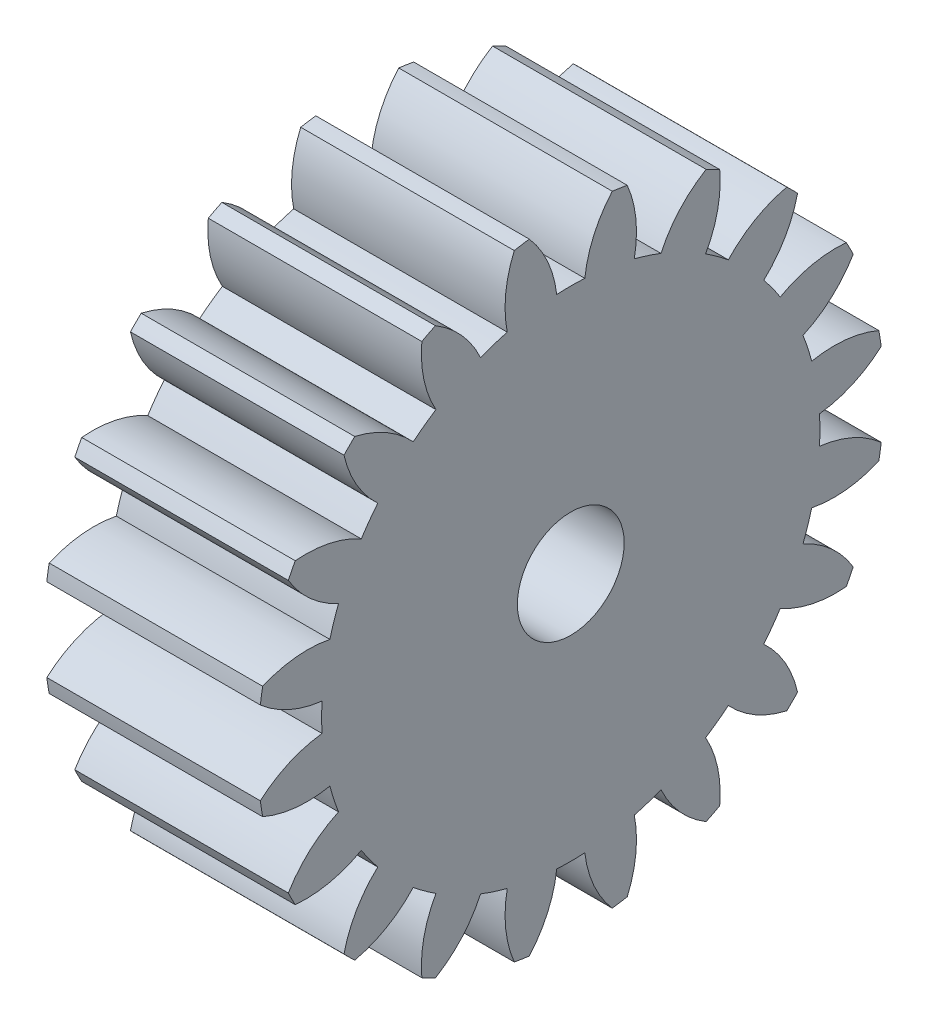
from build123d import *
from build123d.topology import SkipClean

# Parameters (mm, degrees)
BASPROSKE_W                  = 20
BASPROSKE_H                  = 55
TOOTHCUT_DEPTH               = 81.311892021
TEETHCUTS_COUNT              = 20
TEETHCUTS_ANGLE              = 342
BORSKE_R                     = 7.5
BORE_DEPTH                   = 50.0000508
SCALA1_SCALE                 = 0.16
ESTRUSIONE_ESTRUSIONE1_DEPTH = 2.8
SCHIZZO2_R                   = 2.85
TAGLIO_ESTRUSIONE1_DEPTH     = 3.3
SCHIZZO3_R                   = 1.5
TAGLIO_ESTRUSIONE2_DEPTH     = 3.3


with BuildPart() as part:
    # BasProSke → Base-Revolve (revolve)
    with BuildSketch(Plane(origin=(0, 0, 0), x_dir=(1, 0, 0), z_dir=(0, 1, 0))):
        with Locations((10, 27.5)):
            Rectangle(BASPROSKE_W, BASPROSKE_H)
    revolve(axis=Axis((-10, 0, 0), (1, 0, 0)))

    # TooCutSke → ToothCut (cut, through all)
    with BuildSketch(Plane(origin=(0, 0, 0), x_dir=(0, 0, -1), z_dir=(1, 0, 0))):
        with BuildLine():
            ThreePointArc((2.464838288, 43.679509764), (0, 43.749), (-2.464838288, 43.679509764))
            ThreePointArc((-2.464838288, 43.679509764), (-4.057398861, 49.476814676), (-7.300899231, 54.538899105))
            ThreePointArc((-7.300899231, 54.538899105), (0, 55.0254), (7.300899231, 54.538899105))
            ThreePointArc((7.300899231, 54.538899105), (4.057398861, 49.476814676), (2.464838288, 43.679509764))
        make_face()
    toothcut = extrude(amount=TOOTHCUT_DEPTH, mode=Mode.SUBTRACT)

    # TeethCuts: ToothCut ×20 about axis
    teethcuts_axis = Axis((-10, 0, 0), (1, 0, 0))
    for i in range(1, TEETHCUTS_COUNT):
        add(toothcut.rotate(teethcuts_axis, i * TEETHCUTS_ANGLE / (TEETHCUTS_COUNT - 1)), mode=Mode.SUBTRACT)

    # BorSke → Bore (cut, symmetric)
    with BuildSketch(Plane(origin=(0, 0, 0), x_dir=(0, 0, -1), z_dir=(1, 0, 0))):
        Circle(BORSKE_R)
    extrude(amount=BORE_DEPTH, both=True, mode=Mode.SUBTRACT)


with BuildPart() as part_1:
    # Scala1: scaled about (10, 0, 0)
    add(part.part.scale(SCALA1_SCALE).moved(Location((8.4, 0, 0))))

    # Schizzo1 → Estrusione-Estrusione1 (add)
    with SkipClean():  # the faces are left unmerged after this step: merging them gives an invalid solid
        with BuildSketch(Plane(origin=(11.6, 0, 0), x_dir=(0, 0, -1), z_dir=(1, 0, 0))):
            with BuildLine():
                ThreePointArc((-8.722554018, 1.164925493), (-7.914060477, 0.648191798), (-6.988721562, 0.394374126))
                ThreePointArc((-6.988721562, 0.394374126), (-6.99984, 0), (-6.988721562, -0.394374126))
                ThreePointArc((-6.988721562, -0.394374126), (-7.914060477, -0.648191798), (-8.722554018, -1.164925493))
                ThreePointArc((-8.722554018, -1.164925493), (-8.691657397, -1.376623292), (-8.655623612, -1.587507445))
                ThreePointArc((-8.655623612, -1.587507445), (-7.727021068, -1.829112149), (-6.768537489, -1.784561649))
                ThreePointArc((-6.768537489, -1.784561649), (-6.657243445, -2.163069518), (-6.524800875, -2.534705814))
                ThreePointArc((-6.524800875, -2.534705814), (-7.326416506, -3.062046215), (-7.935660063, -3.803327407))
                ThreePointArc((-7.935660063, -3.803327407), (-7.840857413, -3.995116398), (-7.74142046, -4.184544093))
                ThreePointArc((-7.74142046, -4.184544093), (-6.783607, -4.127369854), (-5.885801808, -3.788812097))
                ThreePointArc((-5.885801808, -3.788812097), (-5.662989518, -4.11440272), (-5.422187218, -4.426922837))
                ThreePointArc((-5.422187218, -4.426922837), (-6.021611841, -5.176166214), (-6.37196841, -6.069433135))
                ThreePointArc((-6.37196841, -6.069433135), (-6.222539674, -6.222539674), (-6.069433135, -6.37196841))
                ThreePointArc((-6.069433135, -6.37196841), (-5.176166214, -6.021611841), (-4.426922837, -5.422187218))
                ThreePointArc((-4.426922837, -5.422187218), (-4.11440272, -5.662989518), (-3.788812097, -5.885801808))
                ThreePointArc((-3.788812097, -5.885801808), (-4.127369854, -6.783607), (-4.184544093, -7.74142046))
                ThreePointArc((-4.184544093, -7.74142046), (-3.995116398, -7.840857413), (-3.803327407, -7.935660063))
                ThreePointArc((-3.803327407, -7.935660063), (-3.062046215, -7.326416506), (-2.534705814, -6.524800875))
                ThreePointArc((-2.534705814, -6.524800875), (-2.163069518, -6.657243445), (-1.784561649, -6.768537489))
                ThreePointArc((-1.784561649, -6.768537489), (-1.829112149, -7.727021068), (-1.587507445, -8.655623612))
                ThreePointArc((-1.587507445, -8.655623612), (-1.376623292, -8.691657397), (-1.164925493, -8.722554018))
                ThreePointArc((-1.164925493, -8.722554018), (-0.648191798, -7.914060477), (-0.394374126, -6.988721562))
                ThreePointArc((-0.394374126, -6.988721562), (0, -6.99984), (0.394374126, -6.988721562))
                ThreePointArc((0.394374126, -6.988721562), (0.648191798, -7.914060477), (1.164925493, -8.722554018))
                ThreePointArc((1.164925493, -8.722554018), (1.376623292, -8.691657397), (1.587507445, -8.655623612))
                ThreePointArc((1.587507445, -8.655623612), (1.829112149, -7.727021068), (1.784561649, -6.768537489))
                ThreePointArc((1.784561649, -6.768537489), (2.163069518, -6.657243445), (2.534705814, -6.524800875))
                ThreePointArc((2.534705814, -6.524800875), (3.062046215, -7.326416506), (3.803327407, -7.935660063))
                ThreePointArc((3.803327407, -7.935660063), (3.995116398, -7.840857413), (4.184544093, -7.74142046))
                ThreePointArc((4.184544093, -7.74142046), (4.127369854, -6.783607), (3.788812097, -5.885801808))
                ThreePointArc((3.788812097, -5.885801808), (4.11440272, -5.662989518), (4.426922837, -5.422187218))
                ThreePointArc((4.426922837, -5.422187218), (5.176166214, -6.021611841), (6.069433135, -6.37196841))
                ThreePointArc((6.069433135, -6.37196841), (6.222539674, -6.222539674), (6.37196841, -6.069433135))
                ThreePointArc((6.37196841, -6.069433135), (6.021611841, -5.176166214), (5.422187218, -4.426922837))
                ThreePointArc((5.422187218, -4.426922837), (5.662989518, -4.11440272), (5.885801808, -3.788812097))
                ThreePointArc((5.885801808, -3.788812097), (6.783607, -4.127369854), (7.74142046, -4.184544093))
                ThreePointArc((7.74142046, -4.184544093), (7.840857413, -3.995116398), (7.935660063, -3.803327407))
                ThreePointArc((7.935660063, -3.803327407), (7.326416506, -3.062046215), (6.524800875, -2.534705814))
                ThreePointArc((6.524800875, -2.534705814), (6.657243445, -2.163069518), (6.768537489, -1.784561649))
                ThreePointArc((6.768537489, -1.784561649), (7.727021068, -1.829112149), (8.655623612, -1.587507445))
                ThreePointArc((8.655623612, -1.587507445), (8.691657397, -1.376623292), (8.722554018, -1.164925493))
                ThreePointArc((8.722554018, -1.164925493), (7.914060477, -0.648191798), (6.988721562, -0.394374126))
                ThreePointArc((6.988721562, -0.394374126), (6.99984, 0), (6.988721562, 0.394374126))
                ThreePointArc((6.988721562, 0.394374126), (7.914060477, 0.648191798), (8.722554018, 1.164925493))
                ThreePointArc((8.722554018, 1.164925493), (8.691657397, 1.376623292), (8.655623612, 1.587507445))
                ThreePointArc((8.655623612, 1.587507445), (7.727021068, 1.829112149), (6.768537489, 1.784561649))
                ThreePointArc((6.768537489, 1.784561649), (6.657243445, 2.163069518), (6.524800875, 2.534705814))
                ThreePointArc((6.524800875, 2.534705814), (7.326416506, 3.062046215), (7.935660063, 3.803327407))
                ThreePointArc((7.935660063, 3.803327407), (7.840857413, 3.995116398), (7.74142046, 4.184544093))
                ThreePointArc((7.74142046, 4.184544093), (6.783607, 4.127369854), (5.885801808, 3.788812097))
                ThreePointArc((5.885801808, 3.788812097), (5.662989518, 4.11440272), (5.422187218, 4.426922837))
                ThreePointArc((5.422187218, 4.426922837), (6.021611841, 5.176166214), (6.37196841, 6.069433135))
                ThreePointArc((6.37196841, 6.069433135), (6.222539674, 6.222539674), (6.069433135, 6.37196841))
                ThreePointArc((6.069433135, 6.37196841), (5.176166214, 6.021611841), (4.426922837, 5.422187218))
                ThreePointArc((4.426922837, 5.422187218), (4.11440272, 5.662989518), (3.788812097, 5.885801808))
                ThreePointArc((3.788812097, 5.885801808), (4.127369854, 6.783607), (4.184544093, 7.74142046))
                ThreePointArc((4.184544093, 7.74142046), (3.995116398, 7.840857413), (3.803327407, 7.935660063))
                ThreePointArc((3.803327407, 7.935660063), (3.062046215, 7.326416506), (2.534705814, 6.524800875))
                ThreePointArc((2.534705814, 6.524800875), (2.163069518, 6.657243445), (1.784561649, 6.768537489))
                ThreePointArc((1.784561649, 6.768537489), (1.829112149, 7.727021068), (1.587507445, 8.655623612))
                ThreePointArc((1.587507445, 8.655623612), (1.376623292, 8.691657397), (1.164925493, 8.722554018))
                ThreePointArc((1.164925493, 8.722554018), (0.648191798, 7.914060477), (0.394374126, 6.988721562))
                ThreePointArc((0.394374126, 6.988721562), (0, 6.99984), (-0.394374126, 6.988721562))
                ThreePointArc((-0.394374126, 6.988721562), (-0.648191798, 7.914060477), (-1.164925493, 8.722554018))
                ThreePointArc((-1.164925493, 8.722554018), (-1.376623292, 8.691657397), (-1.587507445, 8.655623612))
                ThreePointArc((-1.587507445, 8.655623612), (-1.829112149, 7.727021068), (-1.784561649, 6.768537489))
                ThreePointArc((-1.784561649, 6.768537489), (-2.163069518, 6.657243445), (-2.534705814, 6.524800875))
                ThreePointArc((-2.534705814, 6.524800875), (-3.062046215, 7.326416506), (-3.803327407, 7.935660063))
                ThreePointArc((-3.803327407, 7.935660063), (-3.995116398, 7.840857413), (-4.184544093, 7.74142046))
                ThreePointArc((-4.184544093, 7.74142046), (-4.127369854, 6.783607), (-3.788812097, 5.885801808))
                ThreePointArc((-3.788812097, 5.885801808), (-4.11440272, 5.662989518), (-4.426922837, 5.422187218))
                ThreePointArc((-4.426922837, 5.422187218), (-5.176166214, 6.021611841), (-6.069433135, 6.37196841))
                ThreePointArc((-6.069433135, 6.37196841), (-6.222539674, 6.222539674), (-6.37196841, 6.069433135))
                ThreePointArc((-6.37196841, 6.069433135), (-6.021611841, 5.176166214), (-5.422187218, 4.426922837))
                ThreePointArc((-5.422187218, 4.426922837), (-5.662989518, 4.11440272), (-5.885801808, 3.788812097))
                ThreePointArc((-5.885801808, 3.788812097), (-6.783607, 4.127369854), (-7.74142046, 4.184544093))
                ThreePointArc((-7.74142046, 4.184544093), (-7.840857413, 3.995116398), (-7.935660063, 3.803327407))
                ThreePointArc((-7.935660063, 3.803327407), (-7.326416506, 3.062046215), (-6.524800875, 2.534705814))
                ThreePointArc((-6.524800875, 2.534705814), (-6.657243445, 2.163069518), (-6.768537489, 1.784561649))
                ThreePointArc((-6.768537489, 1.784561649), (-7.727021068, 1.829112149), (-8.655623612, 1.587507445))
                ThreePointArc((-8.655623612, 1.587507445), (-8.691657397, 1.376623292), (-8.722554018, 1.164925493))
            make_face()
        extrude(amount=ESTRUSIONE_ESTRUSIONE1_DEPTH)

    # Schizzo2 → Taglio-Estrusione1 (cut)
    with SkipClean():  # the faces are left unmerged after this step: merging them gives an invalid solid
        with BuildSketch(Plane.ZY.offset(-8.4)):
            Circle(SCHIZZO2_R)
        extrude(amount=-TAGLIO_ESTRUSIONE1_DEPTH, mode=Mode.SUBTRACT)

    # Schizzo3 → Taglio-Estrusione2 (cut)
    with SkipClean():  # the faces are left unmerged after this step: merging them gives an invalid solid
        with BuildSketch(Plane.ZY.offset(-11.7)):
            Circle(SCHIZZO3_R)
        extrude(amount=-TAGLIO_ESTRUSIONE2_DEPTH, mode=Mode.SUBTRACT)


solid = part_1.part
